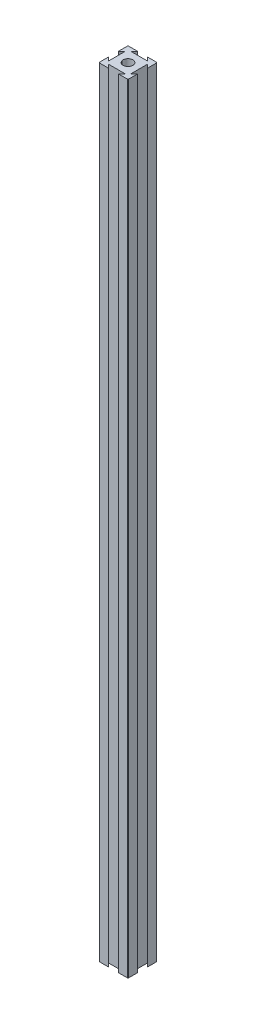
from build123d import *

# Parameters (mm, degrees)
SKETCH1_R           = 3.333333333
BOSS_EXTRUDE1_DEPTH = 533.4
FILLET4_R           = 0.508


with BuildPart() as part:
    # Sketch1 → Boss-Extrude1 (new body)
    with BuildSketch(Plane(origin=(0, 0, 0), x_dir=(1, 0, 0), z_dir=(0, 1, 0))):
        Polygon((4.285, 17.618333333), (6.666666667, 20), (0, 20), (0, 13.333333333), (2.381666667, 15.715), (2.381666667, 4.285), (0, 6.666666667), (0, 0), (6.666666667, 0), (4.285, 2.381666667), (15.715, 2.381666667), (13.333333333, 0), (20, 0), (20, 6.666666667), (17.618333333, 4.285), (17.618333333, 15.715), (20, 13.333333333), (20, 20), (13.333333333, 20), (15.715, 17.618333333), align=None)
        with Locations((10, 10)):
            Circle(SKETCH1_R, mode=Mode.SUBTRACT)
    extrude(amount=BOSS_EXTRUDE1_DEPTH)

    # Fillet4
    fillet4_edges = [part.edges().sort_by_distance(p)[0] for p in [
        (20, 266.7, 0),
        (0, 266.7, 0),
        (0, 266.7, -20),
        (20, 266.7, -20),
    ]]
    fillet(fillet4_edges, radius=FILLET4_R)


solid = part.part
